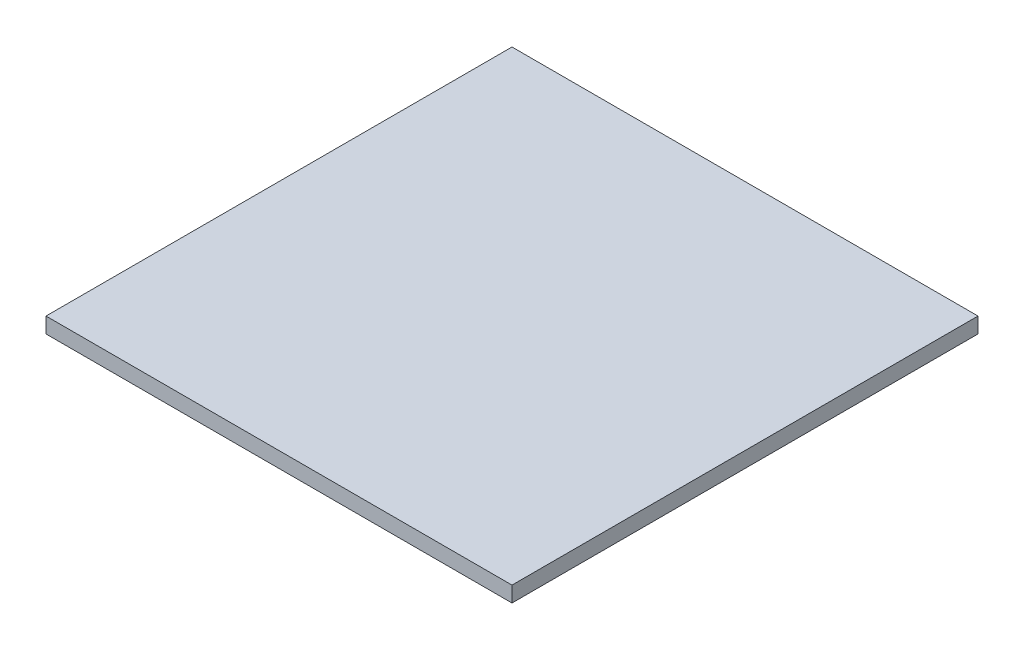
from build123d import *

# Parameters (mm, degrees)
SKETCH1_W           = 300
SKETCH1_H           = 300
BOSS_EXTRUDE1_DEPTH = 10


with BuildPart() as part:
    # Sketch1 → Boss-Extrude1 (new body)
    with BuildSketch(Plane(origin=(0, 0, 0), x_dir=(1, 0, 0), z_dir=(0, 1, 0))):
        Rectangle(SKETCH1_W, SKETCH1_H)
    extrude(amount=BOSS_EXTRUDE1_DEPTH)


solid = part.part
